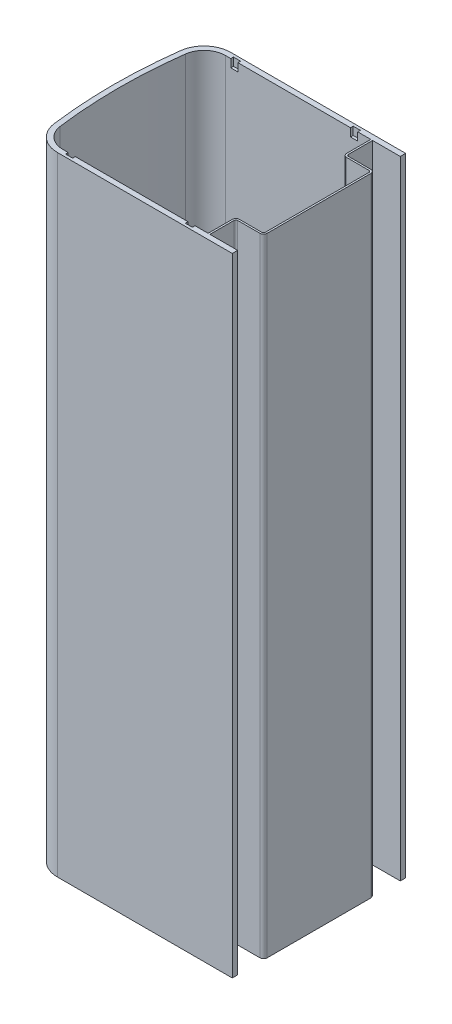
from build123d import *

# Parameters (mm, degrees)
BOSS_EXTRUDE1_DEPTH = 351.07
SKETCH2_W           = 4
SKETCH2_H           = 9
CUT_EXTRUDE1_DEPTH  = 1.5
BOSS_EXTRUDE2_DEPTH = 351.07


with BuildPart() as part:
    # Sketch1 → Boss-Extrude1 (new body)
    with BuildSketch(Plane(origin=(0, 0, 0), x_dir=(1, 0, 0), z_dir=(0, 1, 0))):
        with BuildLine():
            Line((-257.832794656, 48.5), (-160, 48.5))
            Line((-160, 48.5), (-160, 45.5))
            Line((-160, 45.5), (-257.832794656, 45.5))
            ThreePointArc((-257.832794656, 45.5), (-265.752584863, 42.515371489), (-269.732769794, 35.046153846))
            ThreePointArc((-269.732769794, 35.046153846), (-272, 0), (-269.732769794, -35.046153846))
            ThreePointArc((-269.732769794, -35.046153846), (-265.752584863, -42.515371489), (-257.832794656, -45.5))
            Line((-257.832794656, -45.5), (-160, -45.5))
            Line((-160, -45.5), (-160, -48.5))
            Line((-160, -48.5), (-257.832794656, -48.5))
            ThreePointArc((-257.832794656, -48.5), (-267.732532415, -44.769214361), (-272.707763578, -35.432692308))
            ThreePointArc((-272.707763578, -35.432692308), (-275, 0), (-272.707763578, 35.432692308))
            ThreePointArc((-272.707763578, 35.432692308), (-267.732532415, 44.769214361), (-257.832794656, 48.5))
        make_face()
    extrude(amount=BOSS_EXTRUDE1_DEPTH)

    # Sketch2 → Cut-Extrude1 (cut)
    with BuildSketch(Plane.XY.offset(-45.5)):
        with Locations((-252.832794656, 351.07)):
            Rectangle(SKETCH2_W, SKETCH2_H)
        with Locations((-185.832794656, 351.07)):
            Rectangle(SKETCH2_W, SKETCH2_H)
    cut_extrude1 = extrude(amount=-CUT_EXTRUDE1_DEPTH, mode=Mode.SUBTRACT)

    # Mirror1: Cut-Extrude1 across plane
    add(cut_extrude1.mirror(Plane.XY), mode=Mode.SUBTRACT)

    # Sketch3 → Boss-Extrude2 (add)
    with BuildSketch(Plane(origin=(0, 351.07, 0), x_dir=(1, 0, 0), z_dir=(0, 1, 0))):
        with BuildLine():
            Line((-176.5, -45.5), (-176.5, -32))
            ThreePointArc((-176.5, -32), (-175.914213562, -30.585786438), (-174.5, -30))
            Line((-174.5, -30), (-162, -30))
            ThreePointArc((-162, -30), (-161.292893219, -29.707106781), (-161, -29))
            Line((-161, -29), (-161, 29))
            ThreePointArc((-161, 29), (-161.292893219, 29.707106781), (-162, 30))
            Line((-162, 30), (-174.5, 30))
            ThreePointArc((-174.5, 30), (-175.914213562, 30.585786438), (-176.5, 32))
            Line((-176.5, 32), (-176.5, 45.5))
            Line((-176.5, 45.5), (-175.5, 45.5))
            Line((-175.5, 45.5), (-175.5, 32))
            ThreePointArc((-175.5, 32), (-175.207106781, 31.292893219), (-174.5, 31))
            Line((-174.5, 31), (-162, 31))
            ThreePointArc((-162, 31), (-160.585786438, 30.414213562), (-160, 29))
            Line((-160, 29), (-160, -29))
            ThreePointArc((-160, -29), (-160.585786438, -30.414213562), (-162, -31))
            Line((-162, -31), (-174.5, -31))
            ThreePointArc((-174.5, -31), (-175.207106781, -31.292893219), (-175.5, -32))
            Line((-175.5, -32), (-175.5, -45.5))
            Line((-175.5, -45.5), (-176.5, -45.5))
        make_face()
    extrude(amount=-BOSS_EXTRUDE2_DEPTH)


solid = part.part
